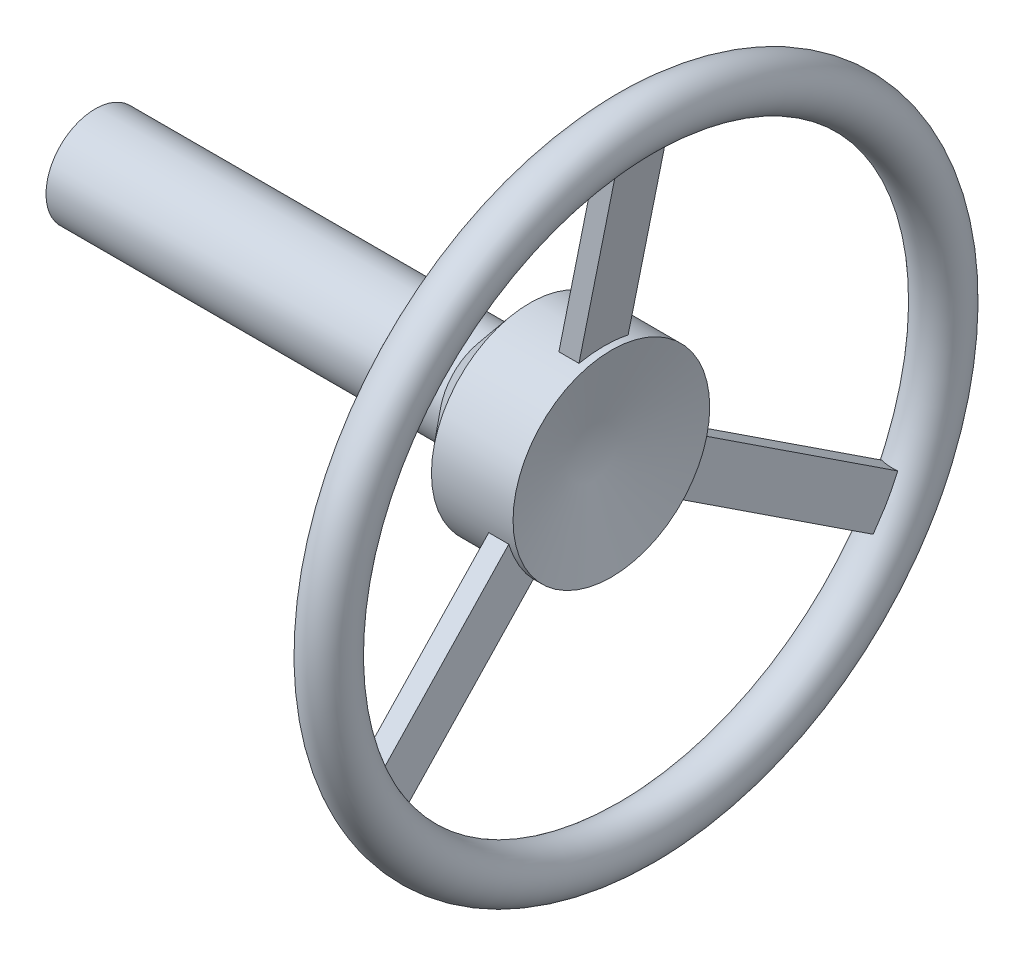
from build123d import *

# Parameters (mm, degrees)
SKETCH2_R           = 2.5
BOSS_EXTRUDE1_DEPTH = 2.5
CIRPATTERN1_COUNT   = 3


with BuildPart() as part:
    # Sketch1 → Revolve1 (revolve)
    with BuildSketch(Plane.XY):
        Polygon((-49.762825818, 0), (-49.762825818, 5), (-9.762825818, 5), (-5.567327662, 10), (2.732672338, 10), (0.206925517, 0), align=None)
    revolve(axis=Axis((-73.695652174, 0, 0), (1, 0, 0)))



with BuildPart() as body_2:
    # Sketch2 → Revolve2 (revolve)
    with BuildSketch(Plane.XY):
        with Locations((5.237174182, 31.25)):
            Circle(SKETCH2_R)
    revolve(axis=Axis((-155.619016335, 0, 0), (1, 0, 0)))


with BuildPart() as part_1:
    add(part.part)

    add(body_2.part)  # Boss-Extrude1 merges body 2
    # Sketch3 → Boss-Extrude1 (add, symmetric)
    with BuildSketch(Plane.XY):
        Polygon((1.837174182, 9.2), (-0.202790977, 9.2), (4.217209023, 31.2), (6.257174182, 31.2), align=None)
    boss_extrude1 = extrude(amount=BOSS_EXTRUDE1_DEPTH, both=True)

    # CirPattern1: Boss-Extrude1 ×3 about axis
    cirpattern1_axis = Axis((0, 0, 0), (1, 0, 0))
    for i in range(1, CIRPATTERN1_COUNT):
        add(boss_extrude1.rotate(cirpattern1_axis, i * 360 / CIRPATTERN1_COUNT))


solid = part_1.part
